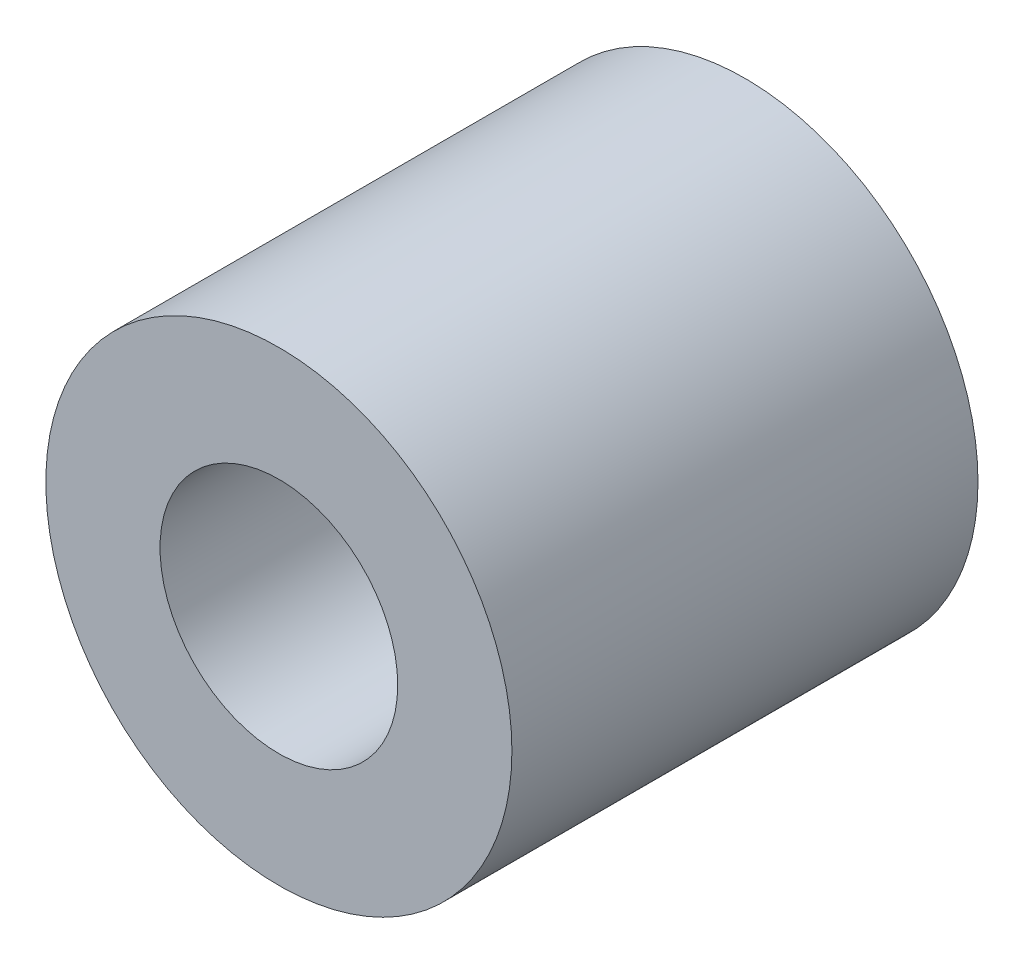
from build123d import *

# Parameters (mm, degrees)
SKETCH1_R           = 12.7
SKETCH1_R_2         = 6.477
EXTRUDE1_DEPTH      = 12.7
EXTRUDE1_DEPTH_BACK = 12.7


with BuildPart() as part:
    # Sketch1 → Extrude1 (new body, two sides)
    with BuildSketch(Plane.XY) as extrude1_sk:
        Circle(SKETCH1_R)
        Circle(SKETCH1_R_2, mode=Mode.SUBTRACT)
    extrude(amount=EXTRUDE1_DEPTH)
    extrude(extrude1_sk.sketch, amount=-EXTRUDE1_DEPTH_BACK)


solid = part.part
